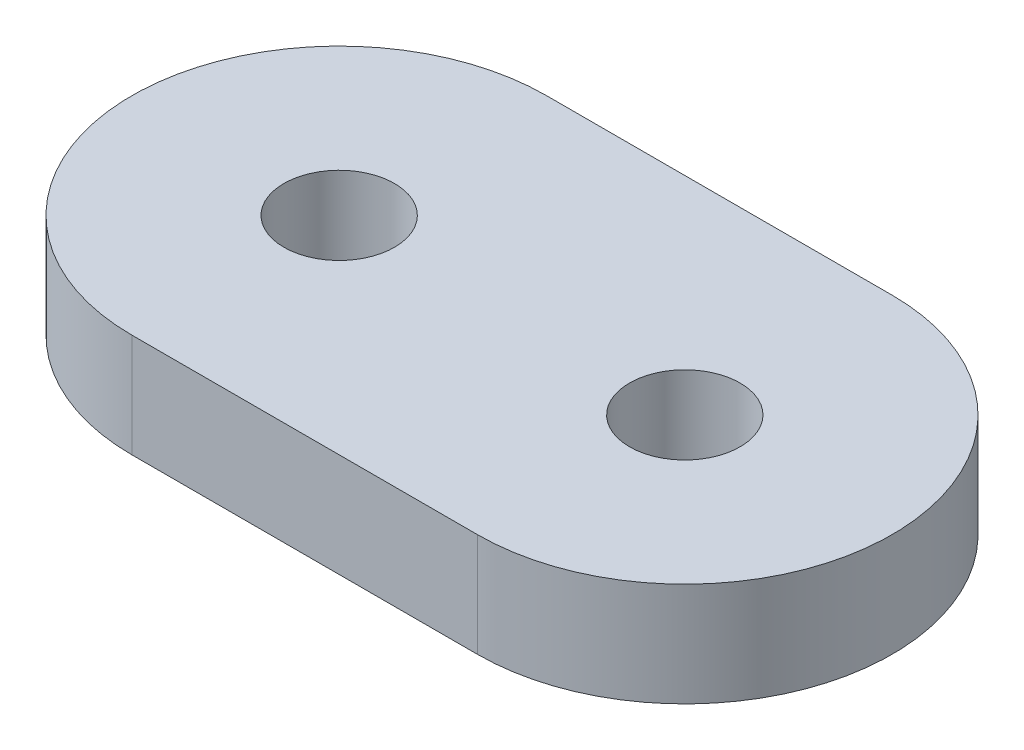
from build123d import *

# Parameters (mm, degrees)
BOSS_EXTRUDE1_DEPTH      = 1.5
M3_CLEARANCE_HOLE1_D     = 3.2
M3_CLEARANCE_HOLE1_DEPTH = 3


with BuildPart() as part:
    # Sketch1 → Boss-Extrude1 (new body, symmetric)
    with BuildSketch(Plane(origin=(0, 0, 0), x_dir=(1, 0, 0), z_dir=(0, 1, 0))):
        with BuildLine():
            Line((-5, 6), (5, 6))
            ThreePointArc((5, 6), (11, 0), (5, -6))
            Line((5, -6), (-5, -6))
            ThreePointArc((-5, -6), (-11, 0), (-5, 6))
        make_face()
    extrude(amount=BOSS_EXTRUDE1_DEPTH, both=True)

    # M3 Clearance Hole1
    with Locations(Plane(origin=(0, 1.5, 0), x_dir=(1, 0, 0), z_dir=(0, 1, 0))):
        with Locations((-5, 0), (5, 0)):
            Hole(M3_CLEARANCE_HOLE1_D / 2, depth=M3_CLEARANCE_HOLE1_DEPTH)


solid = part.part
